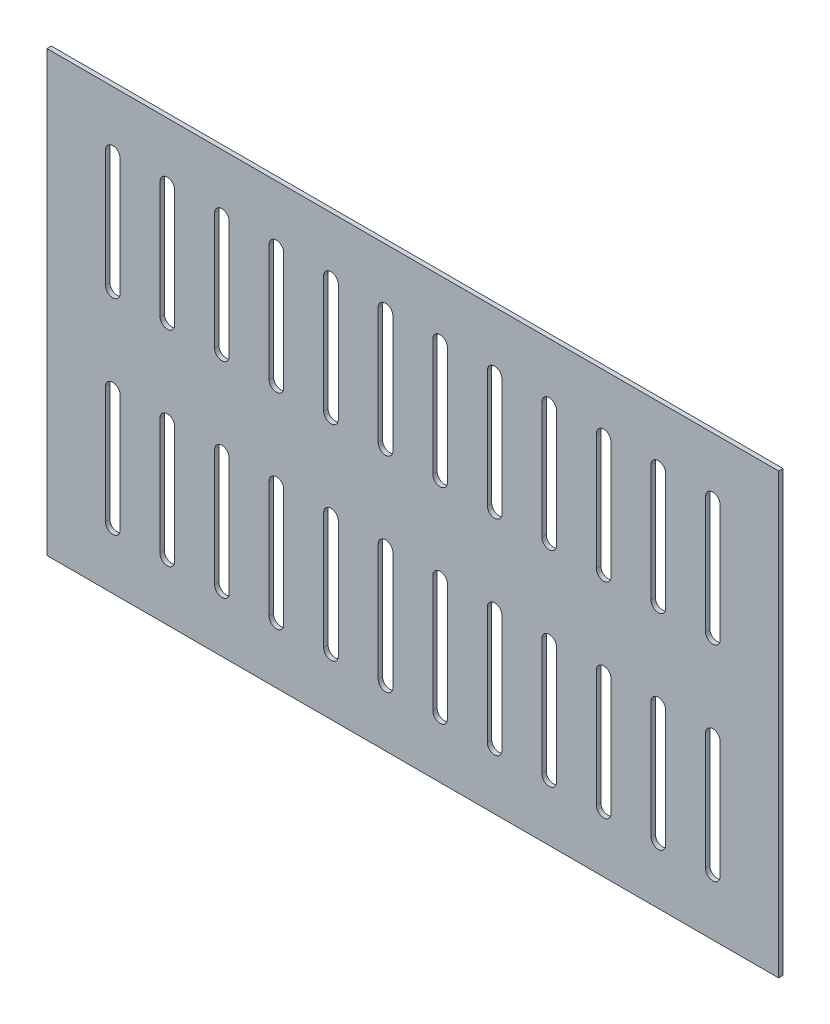
from build123d import *

# Parameters (mm, degrees)
IZIM1_W                     = 500
IZIM1_H                     = 300
Y_KSEKLIK_EKSTR_ZYON1_DEPTH = 3


with BuildPart() as part:
    # Çizim1 → Yükseklik-Ekstrüzyon1 (new body)
    with BuildSketch(Plane.XY):
        with Locations((250, -150)):
            Rectangle(IZIM1_W, IZIM1_H)
        with BuildLine():
            Line((50, -40), (50, -120))
            ThreePointArc((50, -120), (45, -125), (40, -120))
            Line((40, -120), (40, -40))
            ThreePointArc((40, -40), (45, -35), (50, -40))
        make_face(mode=Mode.SUBTRACT)
        with BuildLine():
            Line((87.272727273, -40), (87.272727273, -120))
            ThreePointArc((87.272727273, -120), (82.272727273, -125), (77.272727273, -120))
            Line((77.272727273, -120), (77.272727273, -40))
            ThreePointArc((77.272727273, -40), (82.272727273, -35), (87.272727273, -40))
        make_face(mode=Mode.SUBTRACT)
        with BuildLine():
            Line((124.545454545, -40), (124.545454545, -120))
            ThreePointArc((124.545454545, -120), (119.545454545, -125), (114.545454545, -120))
            Line((114.545454545, -120), (114.545454545, -40))
            ThreePointArc((114.545454545, -40), (119.545454545, -35), (124.545454545, -40))
        make_face(mode=Mode.SUBTRACT)
        with BuildLine():
            Line((161.818181818, -40), (161.818181818, -120))
            ThreePointArc((161.818181818, -120), (156.818181818, -125), (151.818181818, -120))
            Line((151.818181818, -120), (151.818181818, -40))
            ThreePointArc((151.818181818, -40), (156.818181818, -35), (161.818181818, -40))
        make_face(mode=Mode.SUBTRACT)
        with BuildLine():
            Line((199.090909091, -40), (199.090909091, -120))
            ThreePointArc((199.090909091, -120), (194.090909091, -125), (189.090909091, -120))
            Line((189.090909091, -120), (189.090909091, -40))
            ThreePointArc((189.090909091, -40), (194.090909091, -35), (199.090909091, -40))
        make_face(mode=Mode.SUBTRACT)
        with BuildLine():
            Line((236.363636364, -40), (236.363636364, -120))
            ThreePointArc((236.363636364, -120), (231.363636364, -125), (226.363636364, -120))
            Line((226.363636364, -120), (226.363636364, -40))
            ThreePointArc((226.363636364, -40), (231.363636364, -35), (236.363636364, -40))
        make_face(mode=Mode.SUBTRACT)
        with BuildLine():
            Line((273.636363636, -40), (273.636363636, -120))
            ThreePointArc((273.636363636, -120), (268.636363636, -125), (263.636363636, -120))
            Line((263.636363636, -120), (263.636363636, -40))
            ThreePointArc((263.636363636, -40), (268.636363636, -35), (273.636363636, -40))
        make_face(mode=Mode.SUBTRACT)
        with BuildLine():
            Line((310.909090909, -40), (310.909090909, -120))
            ThreePointArc((310.909090909, -120), (305.909090909, -125), (300.909090909, -120))
            Line((300.909090909, -120), (300.909090909, -40))
            ThreePointArc((300.909090909, -40), (305.909090909, -35), (310.909090909, -40))
        make_face(mode=Mode.SUBTRACT)
        with BuildLine():
            Line((348.181818182, -40), (348.181818182, -120))
            ThreePointArc((348.181818182, -120), (343.181818182, -125), (338.181818182, -120))
            Line((338.181818182, -120), (338.181818182, -40))
            ThreePointArc((338.181818182, -40), (343.181818182, -35), (348.181818182, -40))
        make_face(mode=Mode.SUBTRACT)
        with BuildLine():
            Line((385.454545455, -40), (385.454545455, -120))
            ThreePointArc((385.454545455, -120), (380.454545455, -125), (375.454545455, -120))
            Line((375.454545455, -120), (375.454545455, -40))
            ThreePointArc((375.454545455, -40), (380.454545455, -35), (385.454545455, -40))
        make_face(mode=Mode.SUBTRACT)
        with BuildLine():
            Line((422.727272727, -40), (422.727272727, -120))
            ThreePointArc((422.727272727, -120), (417.727272727, -125), (412.727272727, -120))
            Line((412.727272727, -120), (412.727272727, -40))
            ThreePointArc((412.727272727, -40), (417.727272727, -35), (422.727272727, -40))
        make_face(mode=Mode.SUBTRACT)
        with BuildLine():
            Line((460, -40), (460, -120))
            ThreePointArc((460, -120), (455, -125), (450, -120))
            Line((450, -120), (450, -40))
            ThreePointArc((450, -40), (455, -35), (460, -40))
        make_face(mode=Mode.SUBTRACT)
        with BuildLine():
            Line((87.272727273, -180), (87.272727273, -260))
            ThreePointArc((87.272727273, -260), (82.272727273, -265), (77.272727273, -260))
            Line((77.272727273, -260), (77.272727273, -180))
            ThreePointArc((77.272727273, -180), (82.272727273, -175), (87.272727273, -180))
        make_face(mode=Mode.SUBTRACT)
        with BuildLine():
            Line((124.545454545, -180), (124.545454545, -260))
            ThreePointArc((124.545454545, -260), (119.545454545, -265), (114.545454545, -260))
            Line((114.545454545, -260), (114.545454545, -180))
            ThreePointArc((114.545454545, -180), (119.545454545, -175), (124.545454545, -180))
        make_face(mode=Mode.SUBTRACT)
        with BuildLine():
            Line((161.818181818, -180), (161.818181818, -260))
            ThreePointArc((161.818181818, -260), (156.818181818, -265), (151.818181818, -260))
            Line((151.818181818, -260), (151.818181818, -180))
            ThreePointArc((151.818181818, -180), (156.818181818, -175), (161.818181818, -180))
        make_face(mode=Mode.SUBTRACT)
        with BuildLine():
            Line((199.090909091, -180), (199.090909091, -260))
            ThreePointArc((199.090909091, -260), (194.090909091, -265), (189.090909091, -260))
            Line((189.090909091, -260), (189.090909091, -180))
            ThreePointArc((189.090909091, -180), (194.090909091, -175), (199.090909091, -180))
        make_face(mode=Mode.SUBTRACT)
        with BuildLine():
            Line((236.363636364, -180), (236.363636364, -260))
            ThreePointArc((236.363636364, -260), (231.363636364, -265), (226.363636364, -260))
            Line((226.363636364, -260), (226.363636364, -180))
            ThreePointArc((226.363636364, -180), (231.363636364, -175), (236.363636364, -180))
        make_face(mode=Mode.SUBTRACT)
        with BuildLine():
            Line((273.636363636, -180), (273.636363636, -260))
            ThreePointArc((273.636363636, -260), (268.636363636, -265), (263.636363636, -260))
            Line((263.636363636, -260), (263.636363636, -180))
            ThreePointArc((263.636363636, -180), (268.636363636, -175), (273.636363636, -180))
        make_face(mode=Mode.SUBTRACT)
        with BuildLine():
            Line((310.909090909, -180), (310.909090909, -260))
            ThreePointArc((310.909090909, -260), (305.909090909, -265), (300.909090909, -260))
            Line((300.909090909, -260), (300.909090909, -180))
            ThreePointArc((300.909090909, -180), (305.909090909, -175), (310.909090909, -180))
        make_face(mode=Mode.SUBTRACT)
        with BuildLine():
            Line((348.181818182, -180), (348.181818182, -260))
            ThreePointArc((348.181818182, -260), (343.181818182, -265), (338.181818182, -260))
            Line((338.181818182, -260), (338.181818182, -180))
            ThreePointArc((338.181818182, -180), (343.181818182, -175), (348.181818182, -180))
        make_face(mode=Mode.SUBTRACT)
        with BuildLine():
            Line((385.454545455, -180), (385.454545455, -260))
            ThreePointArc((385.454545455, -260), (380.454545455, -265), (375.454545455, -260))
            Line((375.454545455, -260), (375.454545455, -180))
            ThreePointArc((375.454545455, -180), (380.454545455, -175), (385.454545455, -180))
        make_face(mode=Mode.SUBTRACT)
        with BuildLine():
            Line((422.727272727, -180), (422.727272727, -260))
            ThreePointArc((422.727272727, -260), (417.727272727, -265), (412.727272727, -260))
            Line((412.727272727, -260), (412.727272727, -180))
            ThreePointArc((412.727272727, -180), (417.727272727, -175), (422.727272727, -180))
        make_face(mode=Mode.SUBTRACT)
        with BuildLine():
            Line((460, -180), (460, -260))
            ThreePointArc((460, -260), (455, -265), (450, -260))
            Line((450, -260), (450, -180))
            ThreePointArc((450, -180), (455, -175), (460, -180))
        make_face(mode=Mode.SUBTRACT)
        with BuildLine():
            Line((50, -180), (50, -260))
            ThreePointArc((50, -260), (45, -265), (40, -260))
            Line((40, -260), (40, -180))
            ThreePointArc((40, -180), (45, -175), (50, -180))
        make_face(mode=Mode.SUBTRACT)
    extrude(amount=Y_KSEKLIK_EKSTR_ZYON1_DEPTH)


solid = part.part
